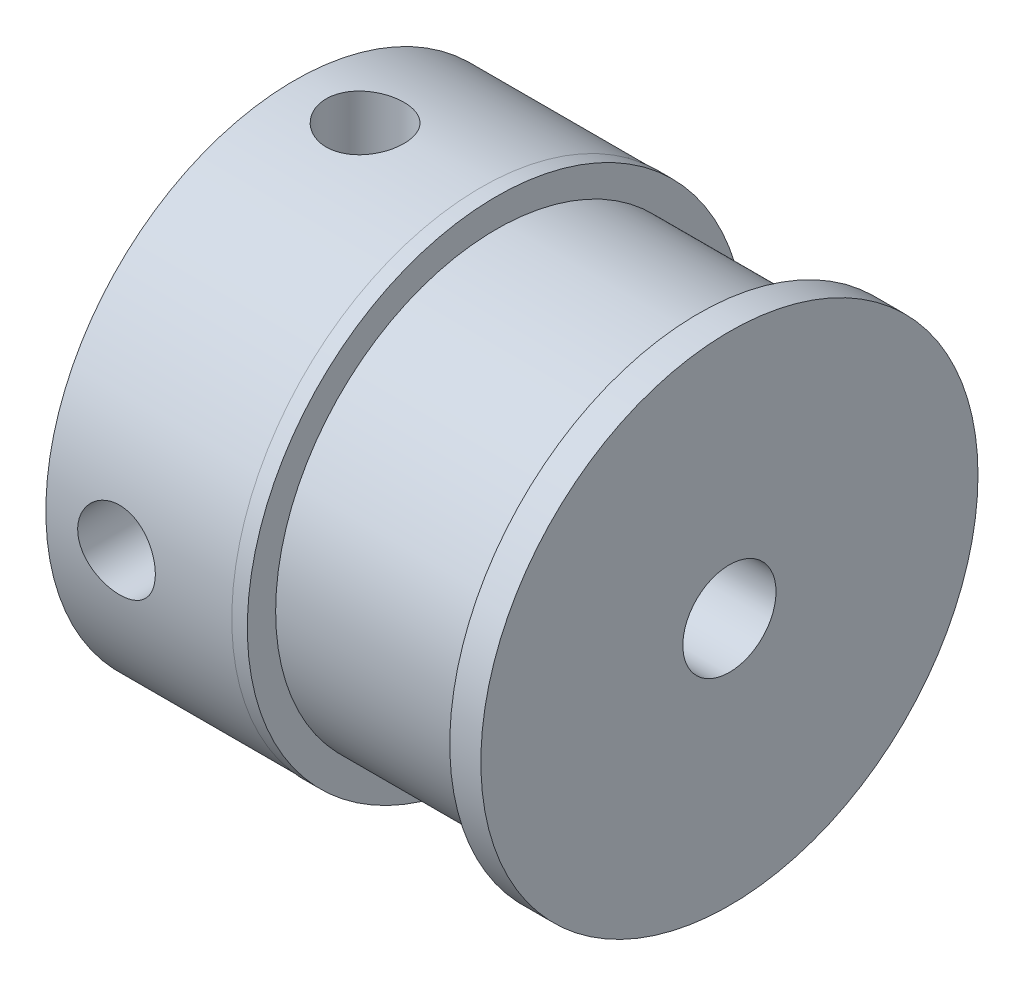
from build123d import *

# Parameters (mm, degrees)
SKETCH2_W = 1.25
SKETCH2_H = 8.015739734
SKETCH4_W = 1.25
SKETCH4_H = 8.015739734


with BuildPart() as part:
    # Sketch1 → Revolve1 (revolve)
    with BuildSketch(Plane.XY):
        Polygon((1.451473536, 1.5), (1.451473536, 8), (7.451473536, 8), (7.451473536, 8.015739734), (7.951473536, 8.015739734), (7.951473536, 7.104033654), (14.451473536, 7.104033654), (14.451473536, 8), (15.451473536, 8), (15.451473536, 1.5), align=None)
    revolve(axis=Axis((0, 0, 0), (-1, 0, 0)))

    # Sketch2 → M3x0.5 Tapped Hole1 (revolve, cut)
    with BuildSketch(Plane(origin=(3.725736768, 0, 0), x_dir=(0, 0, -1), z_dir=(1, 0, 0))):
        with Locations((0.625, 4.007869867)):
            Rectangle(SKETCH2_W, SKETCH2_H)
    revolve(axis=Axis((3.725736768, -6.35, 0), (0, 1, 0)), mode=Mode.SUBTRACT)

    # Sketch4 → M3x0.5 Tapped Hole2 (revolve, cut)
    with BuildSketch(Plane.YZ.offset(3.725736768)):
        with Locations((0.625, 4.007869867)):
            Rectangle(SKETCH4_W, SKETCH4_H)
    revolve(axis=Axis((3.725736768, 0, -6.35), (0, 0, 1)), mode=Mode.SUBTRACT)


solid = part.part
